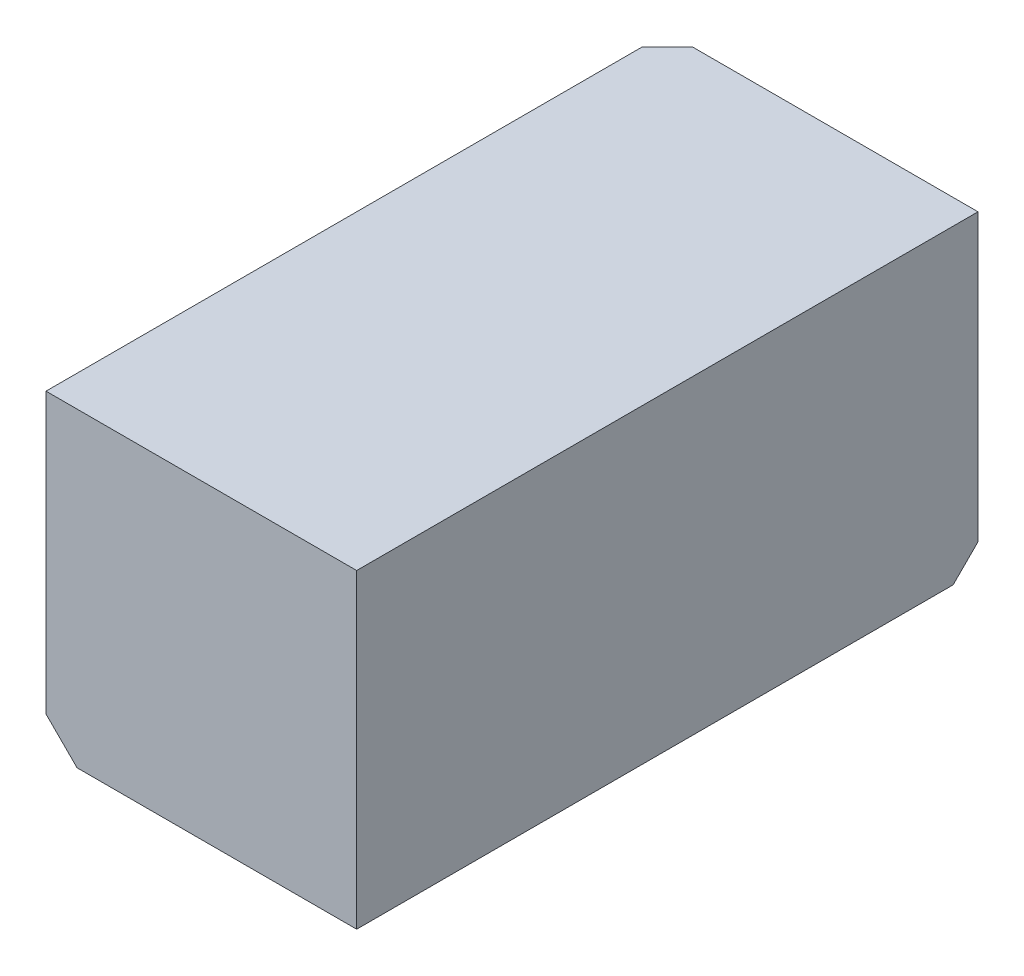
from build123d import *

# Parameters (mm, degrees)
SKETCH1_W           = 5
SKETCH1_H           = 5
BOSS_EXTRUDE1_DEPTH = 10
SKETCH4_R           = 1.6
CUT_EXTRUDE3_DEPTH  = 4.5
SKETCH5_R           = 1.6
CUT_EXTRUDE4_DEPTH  = 4.5
CHAMFER1_SIZE       = 0.5
CHAMFER4_SIZE       = 0.4


with BuildPart() as part:
    # Sketch1 → Boss-Extrude1 (new body)
    with BuildSketch(Plane.XY):
        Rectangle(SKETCH1_W, SKETCH1_H)
    extrude(amount=BOSS_EXTRUDE1_DEPTH)

    # Sketch4 → Cut-Extrude3 (cut)
    with BuildSketch(Plane.XZ.offset(2.5)):
        with Locations((0, 7.5)):
            Circle(SKETCH4_R)
    extrude(amount=-CUT_EXTRUDE3_DEPTH, mode=Mode.SUBTRACT)

    # Sketch5 → Cut-Extrude4 (cut)
    with BuildSketch(Plane.ZY.offset(2.5)):
        with Locations((2.5, 0)):
            Circle(SKETCH5_R)
    extrude(amount=-CUT_EXTRUDE4_DEPTH, mode=Mode.SUBTRACT)

    # Chamfer1
    chamfer1_edges = [part.edges().sort_by_distance(p)[0] for p in [
        (-2.5, -2.5, 5),
    ]]
    chamfer(chamfer1_edges, length=CHAMFER1_SIZE)

    # Chamfer4
    chamfer4_edges = [part.edges().sort_by_distance(p)[0] for p in [
        (0.25, -2.5, 0),
        (-2.25, -2.25, 0),
        (-2.5, 0.25, 0),
    ]]
    chamfer(chamfer4_edges, length=CHAMFER4_SIZE)


solid = part.part
